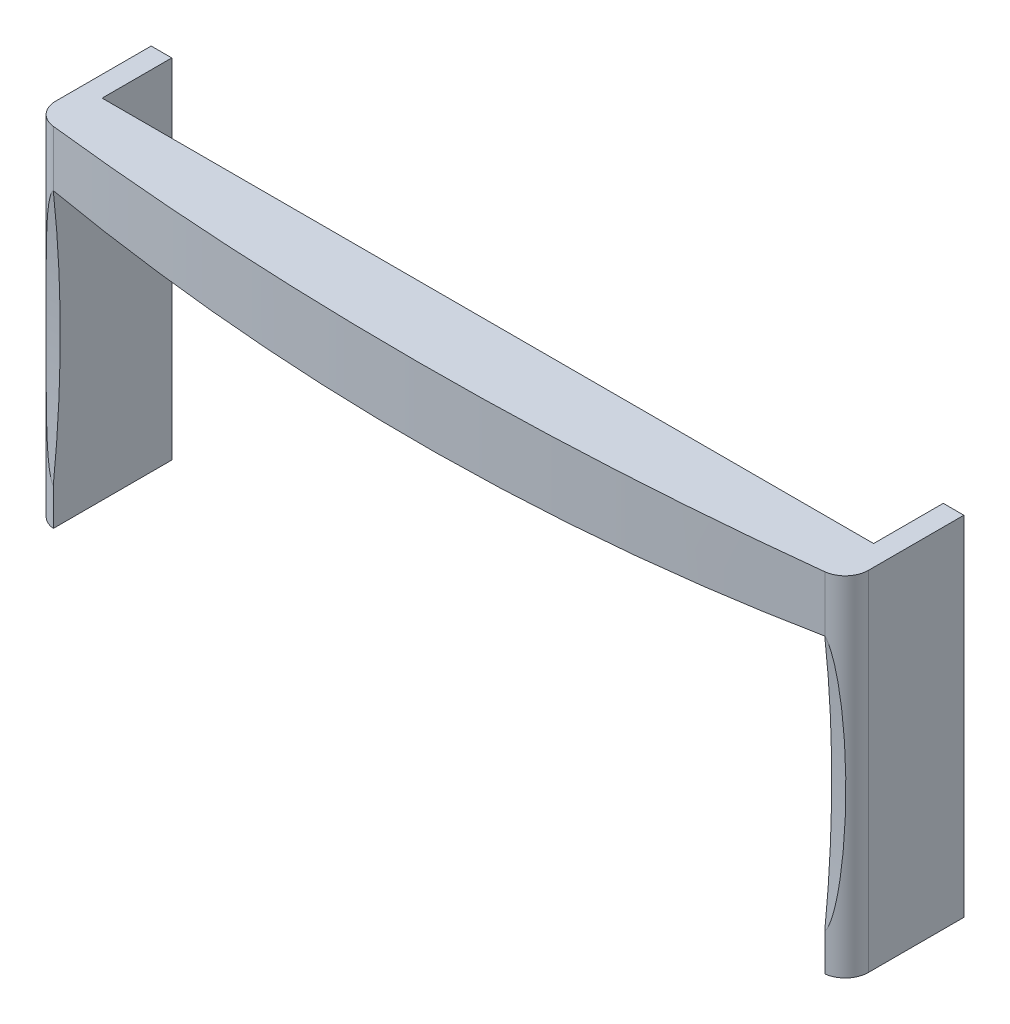
from build123d import *

# Parameters (mm, degrees)
BOSS_EXTRUDE1_DEPTH     = 75
FILLET1_R               = 5
CUT_EXTRUDE1_DEPTH      = 3.701539391
CUT_EXTRUDE1_DEPTH_BACK = 13.5
CUT_EXTRUDE2_DEPTH      = 1
CUT_EXTRUDE2_DEPTH_BACK = 176
SKETCH4_W               = 4.43767441
SKETCH4_H               = 75
BOSS_EXTRUDE2_DEPTH     = 15


with BuildPart() as part:
    # Sketch1 → Boss-Extrude1 (new body)
    with BuildSketch(Plane(origin=(0, 0, 0), x_dir=(1, 0, 0), z_dir=(0, 1, 0))):
        with BuildLine():
            Line((-87.5, 2.5), (-87.5, 12.5))
            Line((-87.5, 12.5), (87.5, 12.5))
            Line((87.5, 12.5), (87.5, 2.5))
            ThreePointArc((87.5, 2.5), (0, -2.701539391), (-87.5, 2.5))
        make_face()
    extrude(amount=BOSS_EXTRUDE1_DEPTH)

    # Fillet1
    fillet1_edges = [part.edges().sort_by_distance(p)[0] for p in [
        (-87.5, 37.5, -2.5),
        (87.5, 37.5, -2.5),
    ]]
    fillet(fillet1_edges, radius=FILLET1_R)

    # Sketch2 → Cut-Extrude1 (cut, two sides)
    with BuildSketch(Plane.XY) as cut_extrude1_sk:
        with BuildLine():
            Line((-83.06232559, 63), (-83.06232559, 0))
            Line((-83.06232559, 0), (83.06232559, 0))
            Line((83.06232559, 0), (83.06232559, 63))
            ThreePointArc((83.06232559, 63), (0, 60), (-83.06232559, 63))
        make_face()
    extrude(amount=CUT_EXTRUDE1_DEPTH, mode=Mode.SUBTRACT)
    extrude(cut_extrude1_sk.sketch, amount=-CUT_EXTRUDE1_DEPTH_BACK, mode=Mode.SUBTRACT)

    # Sketch3 → Cut-Extrude2 (cut, two sides)
    with BuildSketch(Plane.ZY.offset(87.5)) as cut_extrude2_sk:
        with BuildLine():
            Line((-1.984131445, 63), (-1.984131445, 8))
            ThreePointArc((-1.984131445, 8), (-3.484131445, 35.5), (-1.984131445, 63))
        make_face()
    extrude(amount=CUT_EXTRUDE2_DEPTH, mode=Mode.SUBTRACT)
    extrude(cut_extrude2_sk.sketch, amount=-CUT_EXTRUDE2_DEPTH_BACK, mode=Mode.SUBTRACT)

    # Sketch4 → Boss-Extrude2 (add)
    with BuildSketch(Plane(origin=(0, 0, -12.5), x_dir=(-1, 0, 0), z_dir=(0, 0, -1))):
        with Locations((-85.281162795, 37.5)):
            Rectangle(SKETCH4_W, SKETCH4_H)
        with Locations((85.281162795, 37.5)):
            Rectangle(SKETCH4_W, SKETCH4_H)
    extrude(amount=BOSS_EXTRUDE2_DEPTH)


solid = part.part
